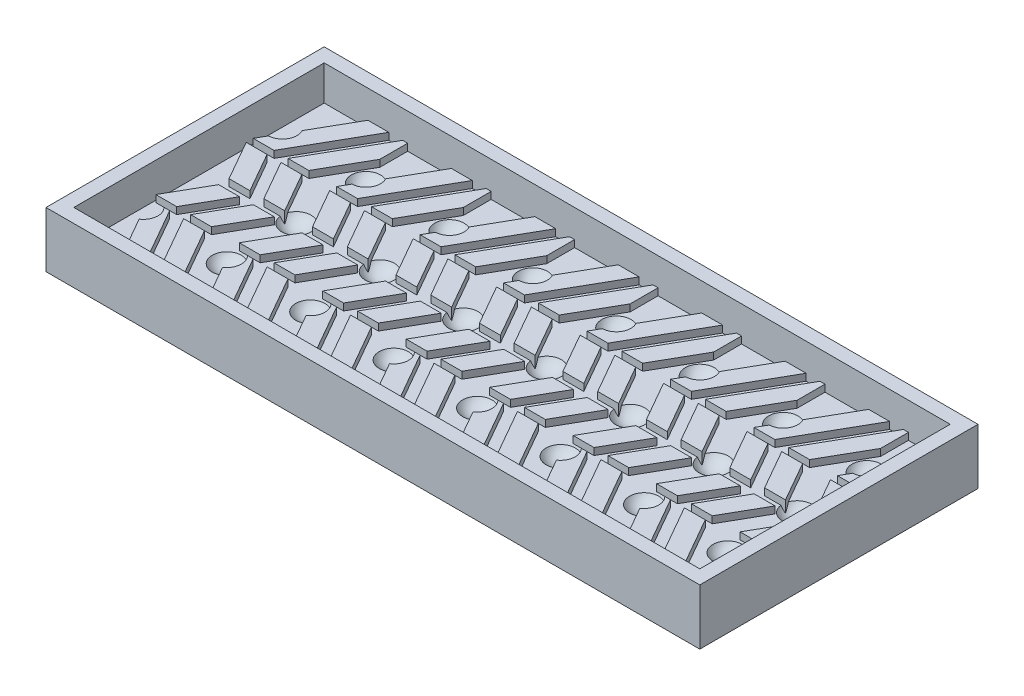
from build123d import *

# Parameters (mm, degrees)
SKETCH1_W               = 132
SKETCH1_H               = 36
BOSS_EXTRUDE1_DEPTH     = 3
REVOLVE1_ANGLE          = 180
LPATTERN2_COUNT         = 10
LPATTERN2_PITCH         = 12
LPATTERN2_COUNT_DIR2    = 3
LPATTERN2_PITCH_DIR2    = 10
CUT_EXTRUDE1_START      = -1
CUT_EXTRUDE1_DEPTH      = 138.853936735
LPATTERN1_COUNT         = 11
LPATTERN1_PITCH         = 12
SKETCH5_W               = 132
SKETCH5_H               = 36
BOSS_EXTRUDE2_DEPTH     = 6
SKETCH6_W               = 136
SKETCH6_H               = 40
SKETCH6_W_2             = 132
SKETCH6_H_2             = 36
BOSS_EXTRUDE3_DEPTH     = 8
SKETCH7_W               = 44
SKETCH7_H               = 40
CUT_EXTRUDE2_DEPTH      = 140.513440213
CUT_EXTRUDE2_DEPTH_BACK = 140.513440213
SKETCH8_W               = 2
SKETCH8_H               = 40
BOSS_EXTRUDE4_DEPTH     = 8


with BuildPart() as part:
    # Sketch1 → Boss-Extrude1 (new body)
    with BuildSketch(Plane(origin=(0, 0, 0), x_dir=(1, 0, 0), z_dir=(0, 1, 0))):
        with Locations((66, 18)):
            Rectangle(SKETCH1_W, SKETCH1_H)
    extrude(amount=BOSS_EXTRUDE1_DEPTH)

    # Sketch4 → Revolve1 (revolve)
    with BuildSketch(Plane(origin=(0, 1.358412268, 0), x_dir=(1, 0, 0), z_dir=(0, 1, 0))):
        with BuildLine():
            ThreePointArc((123.5, 29), (122.767766953, 30.767766953), (121, 31.5))
            Line((121, 31.5), (121, 26.5))
            ThreePointArc((121, 26.5), (122.767766953, 27.232233047), (123.5, 29))
        make_face()
    revolve1 = revolve(axis=Axis((121, 1.358412268, -36), (0, 0, -1)), revolution_arc=REVOLVE1_ANGLE)

    # LPattern2: Revolve1 10 × 3
    with Locations(*[(-i * LPATTERN2_PITCH, 0, j * LPATTERN2_PITCH_DIR2) for i in range(LPATTERN2_COUNT) for j in range(LPATTERN2_COUNT_DIR2) if (i, j) != (0, 0)]):
        add(revolve1)

    # Sketch2 → Cut-Extrude1 (cut)
    with BuildSketch(Plane.XZ.offset(CUT_EXTRUDE1_START)):
        Polygon((132, -36), (132, -32), (128.285714286, -25.5), (125.285714286, -25.5), (131.285714286, -36), align=None)
        Polygon((128.285714286, -24.5), (131.571428571, -18.75), (128.571428571, -18.75), (125.285714286, -24.5), align=None)
        Polygon((128.571428571, -17.25), (131.571428571, -17.25), (128.285714286, -11.5), (125.285714286, -11.5), align=None)
        Polygon((128.285714286, -10.5), (132, -4), (132, 0), (131.285714286, 0), (125.285714286, -10.5), align=None)
        with BuildLine():
            Line((126.285714286, -36), (129.285714286, -36))
            Line((129.285714286, -36), (123.285714286, -25.5))
            Line((123.285714286, -25.5), (120.285714286, -25.5))
            Line((120.285714286, -25.5), (121.08747556, -26.903082229))
            ThreePointArc((121.08747556, -26.903082229), (122.822217961, -27.958732593), (122.850985979, -29.989225463))
            Line((122.850985979, -29.989225463), (126.285714286, -36))
        make_face()
        Polygon((120.285714286, -24.5), (123.285714286, -24.5), (126.571428571, -18.75), (123.571428571, -18.75), align=None)
        Polygon((126.571428571, -17.25), (123.285714286, -11.5), (120.285714286, -11.5), (123.571428571, -17.25), align=None)
        with BuildLine():
            Line((122.467895129, -10.5), (123.285714286, -10.5))
            Line((123.285714286, -10.5), (129.285714286, 0))
            Line((129.285714286, 0), (126.285714286, 0))
            Line((126.285714286, 0), (122.147139675, -7.242505569))
            ThreePointArc((122.147139675, -7.242505569), (123.088640527, -8.794337993), (122.467895129, -10.5))
        make_face()
    cut_extrude1 = extrude(amount=CUT_EXTRUDE1_DEPTH, mode=Mode.SUBTRACT)

    # LPattern1: Cut-Extrude1 ×11
    with Locations(*[(-i * LPATTERN1_PITCH, 0, 0) for i in range(1, LPATTERN1_COUNT)]):
        add(cut_extrude1, mode=Mode.SUBTRACT)


with BuildPart() as body_2:
    # Sketch5 → Boss-Extrude2 (new body)
    with BuildSketch(Plane(origin=(0, 3, 0), x_dir=(1, 0, 0), z_dir=(0, 1, 0))):
        with Locations((66, 18)):
            Rectangle(SKETCH5_W, SKETCH5_H)
    extrude(amount=-BOSS_EXTRUDE2_DEPTH)

    # Combine2: cut part
    add(part.part, mode=Mode.SUBTRACT)

    # Sketch6 → Boss-Extrude3 (add)
    with BuildSketch(Plane.XZ.offset(3)):
        with Locations((66, -18)):
            Rectangle(SKETCH6_W, SKETCH6_H)
        with Locations((66, -18)):
            Rectangle(SKETCH6_W_2, SKETCH6_H_2, mode=Mode.SUBTRACT)
    extrude(amount=-BOSS_EXTRUDE3_DEPTH)

    # Sketch7 → Cut-Extrude2 (cut, two sides)
    with BuildSketch(Plane(origin=(0, 5, 0), x_dir=(1, 0, 0), z_dir=(0, 1, 0))) as cut_extrude2_sk:
        with Locations((112, 18)):
            Rectangle(SKETCH7_W, SKETCH7_H)
    extrude(amount=CUT_EXTRUDE2_DEPTH, mode=Mode.SUBTRACT)
    extrude(cut_extrude2_sk.sketch, amount=-CUT_EXTRUDE2_DEPTH_BACK, mode=Mode.SUBTRACT)

    # Sketch8 → Boss-Extrude4 (add)
    with BuildSketch(Plane.XZ.offset(3)):
        with Locations((91, -18)):
            Rectangle(SKETCH8_W, SKETCH8_H)
    extrude(amount=-BOSS_EXTRUDE4_DEPTH)


solid = body_2.part
